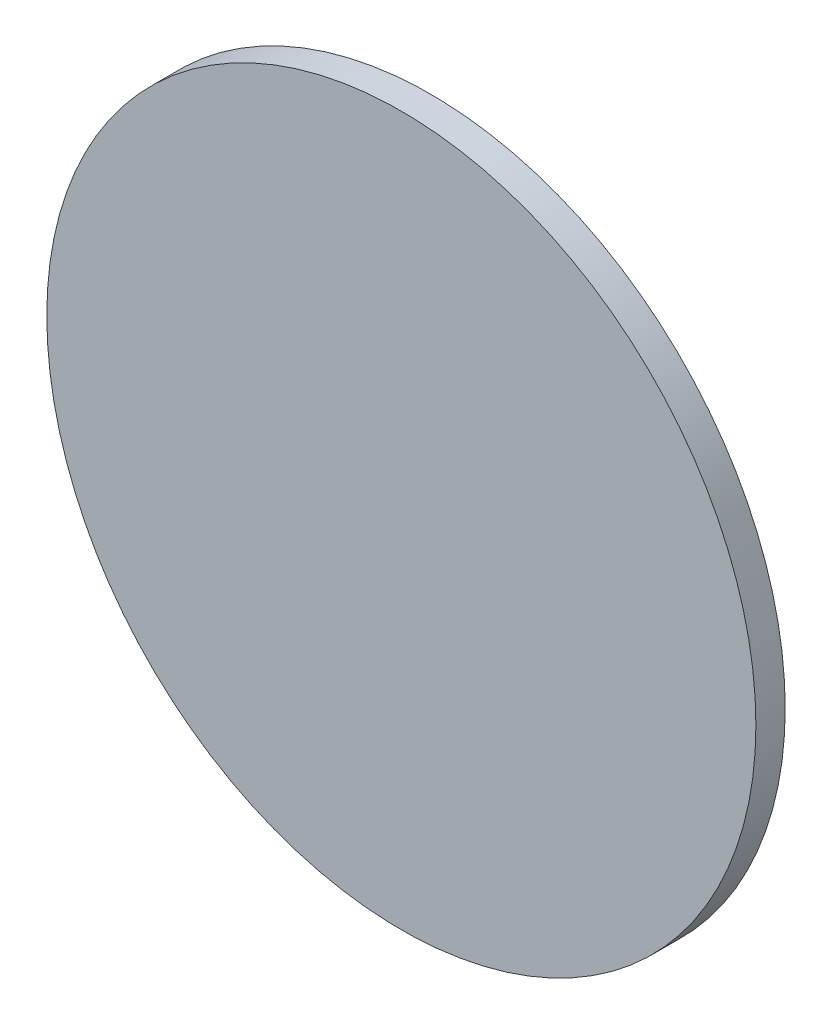
from build123d import *

# Parameters (mm, degrees)
SKETCH1_R      = 9.525
EXTRUDE1_DEPTH = 0.3937


with BuildPart() as part:
    # Sketch1 → Extrude1 (new body, symmetric)
    with BuildSketch(Plane.XY):
        Circle(SKETCH1_R)
    extrude(amount=EXTRUDE1_DEPTH, both=True)


solid = part.part
